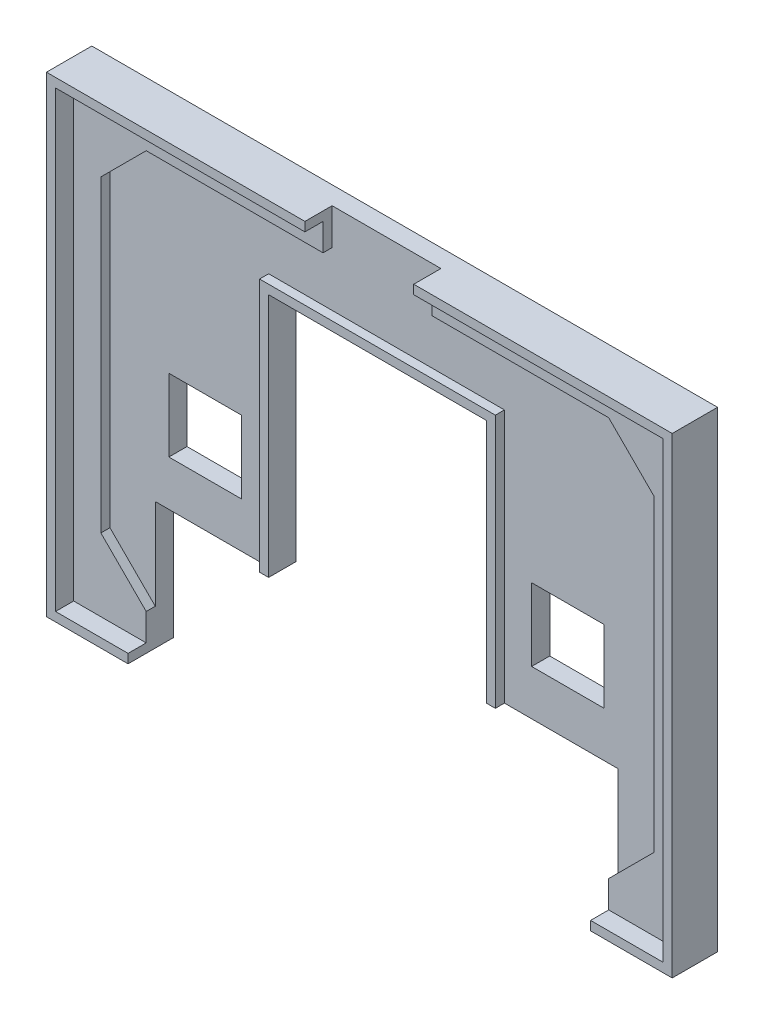
from build123d import *

# Parameters (mm, degrees)
SKICA1_W                    = 67
SKICA1_H                    = 50
P_IDAT_VYSUNUT_M1_DEPTH     = 3
ODEBRAT_VYSUNUT_M1_DEPTH    = 1
SKICA3_W                    = 8
SKICA3_H                    = 8
ODEBRAT_VYSUNUT_M2_DEPTH    = 4
VYSUNOUT_TENKOST_NN_1_DEPTH = 1
VYSUNOUT_TENKOST_NN_2_DEPTH = 5
SKICA6_W                    = 12
SKICA6_H                    = 4
ODEBRAT_VYSUNUT_M3_DEPTH    = 4
ODEBRAT_VYSUNUT_M4_DEPTH    = 1
P_IDAT_START                = -1
SKICA9_W                    = 2
SKICA9_H                    = 2
P_IDAT_VYSUNUT_M3_DEPTH     = 1
ODEBRAT_VYSUNUT_M5_DEPTH    = 1


with BuildPart() as part:
    # Skica1 → Přidat vysunutím1 (new body)
    with BuildSketch(Plane.XY):
        Rectangle(SKICA1_W, SKICA1_H)
    extrude(amount=P_IDAT_VYSUNUT_M1_DEPTH)

    # Skica2 → Odebrat vysunutím1 (cut)
    with BuildSketch(Plane.XY.offset(3)):
        Polygon((-25.5, -22), (-30.5, -17), (-30.5, 17), (-25.5, 22), (25.5, 22), (30.5, 17), (30.5, -17), (25.5, -22), align=None)
    extrude(amount=-ODEBRAT_VYSUNUT_M1_DEPTH, mode=Mode.SUBTRACT)

    # Skica3 → Odebrat vysunutím2 (cut, through all)
    with BuildSketch(Plane(origin=(0, 0, 0), x_dir=(-1, 0, 0), z_dir=(0, 0, -1))):
        with Locations((20, -3)):
            Rectangle(SKICA3_W, SKICA3_H)
        with Locations((-20, -3)):
            Rectangle(SKICA3_W, SKICA3_H)
        Polygon((25.5, -25), (-25.5, -25), (-25.5, -12), (-12, -12), (-12, 15), (12, 15), (12, -12), (25.5, -12), align=None)
    extrude(amount=-ODEBRAT_VYSUNUT_M2_DEPTH, mode=Mode.SUBTRACT)

    # Skica4 → Vysunout tenkostěnný1 (add)
    with BuildSketch(Plane.XY.offset(2)):
        Polygon((-12, -12), (-12, 15), (12, 15), (12, -12), (13, -12), (13, 16), (-13, 16), (-13, -12), align=None)
    extrude(amount=VYSUNOUT_TENKOST_NN_1_DEPTH)

    # Skica5 → Vysunout tenkostěnný2 (add)
    with BuildSketch(Plane(origin=(0, 0, 0), x_dir=(-1, 0, 0), z_dir=(0, 0, -1))):
        Polygon((-25.5, -25), (-33.5, -25), (-33.5, 25), (33.5, 25), (33.5, -25), (25.5, -25), (25.5, -26), (34.5, -26), (34.5, 26), (-34.5, 26), (-34.5, -26), (-25.5, -26), align=None)
    extrude(amount=-VYSUNOUT_TENKOST_NN_2_DEPTH)

    # Skica6 → Odebrat vysunutím3 (cut, through all)
    with BuildSketch(Plane.XY.offset(2)):
        with Locations((0, 24)):
            Rectangle(SKICA6_W, SKICA6_H)
    extrude(amount=ODEBRAT_VYSUNUT_M3_DEPTH, mode=Mode.SUBTRACT)

    # Skica8 → Odebrat vysunutím4 (cut)
    with BuildSketch(Plane(origin=(0, 0, 0), x_dir=(-1, 0, 0), z_dir=(0, 0, -1))):
        Polygon((-30.278743415, 21.328839402), (-28.10976975, 21.328839402), (-28.10976975, 20.22863537), (-27.009565718, 20.22863537), (-27.009565718, 17.996792903), (-19.371006289, 17.996792903), (-19.371006289, 20.22863537), (-18.302236657, 20.22863537), (-18.302236657, 21.328839402), (-15.944656586, 21.328839402), (-15.944656586, 20.22863537), (-14.844452554, 20.22863537), (-14.844452554, 16.833720068), (-15.944656586, 16.833720068), (-15.944656586, 15.702081634), (-14.844452554, 15.702081634), (-14.844452554, 8.943685432), (-15.944656586, 8.943685432), (-15.944656586, 7.969219003), (-17.123446622, 7.969219003), (-17.123446622, 6.806146168), (-18.302236657, 6.806146168), (-18.302236657, 5.737376536), (-28.10976975, 5.737376536), (-28.10976975, 6.806146168), (-29.194256583, 6.806146168), (-29.194256583, 7.969219003), (-30.278743415, 7.969219003), (-30.278743415, 8.943685432), (-31.473250651, 8.943685432), (-31.473250651, 15.702081634), (-30.278743415, 15.702081634), (-30.278743415, 16.833720068), (-31.473250651, 16.833720068), (-31.473250651, 20.22863537), (-30.278743415, 20.22863537), align=None)
        Polygon((15.944656586, 15.702081634), (14.844452554, 15.702081634), (14.844452554, 8.943685432), (15.944656586, 8.943685432), (15.944656586, 7.969219003), (17.123446622, 7.969219003), (17.123446622, 6.806146168), (18.302236657, 6.806146168), (18.302236657, 5.737376536), (28.10976975, 5.737376536), (28.10976975, 6.806146168), (29.194256583, 6.806146168), (29.194256583, 7.969219003), (30.278743415, 7.969219003), (30.278743415, 8.943685432), (31.473250651, 8.943685432), (31.473250651, 15.702081634), (30.278743415, 15.702081634), (30.278743415, 16.833720068), (31.473250651, 16.833720068), (31.473250651, 20.22863537), (30.278743415, 20.22863537), (30.278743415, 21.328839402), (28.10976975, 21.328839402), (28.10976975, 20.22863537), (27.009565718, 20.22863537), (27.009565718, 17.996792903), (19.371006289, 17.996792903), (19.371006289, 20.22863537), (18.302236657, 20.22863537), (18.302236657, 21.328839402), (15.944656586, 21.328839402), (15.944656586, 20.22863537), (14.844452554, 20.22863537), (14.844452554, 16.833720068), (15.944656586, 16.833720068), align=None)
    extrude(amount=-ODEBRAT_VYSUNUT_M4_DEPTH, mode=Mode.SUBTRACT)

    # Skica9 → Přidat vysunutím3 (add)
    with BuildSketch(Plane(origin=(0, 0, 0), x_dir=(-1, 0, 0), z_dir=(0, 0, -1)).offset(P_IDAT_START)):
        with Locations((-26.964723749, 13.702081634)):
            Rectangle(SKICA9_W, SKICA9_H)
        with Locations((-19.415848257, 13.702081634)):
            Rectangle(SKICA9_W, SKICA9_H)
        Polygon((-24.98757766, 11.151300523), (-21.392994346, 11.151300523), (-21.392994346, 10.145181963), (-22.505020123, 10.145181963), (-22.505020123, 7.391594326), (-23.875551884, 7.391594326), (-23.875551884, 10.145181963), (-24.98757766, 10.145181963), align=None)
        Polygon((23.875551884, 7.391594326), (23.875551884, 10.145181963), (24.98757766, 10.145181963), (24.98757766, 11.151300523), (21.392994346, 11.151300523), (21.392994346, 10.145181963), (22.505020123, 10.145181963), (22.505020123, 7.391594326), align=None)
        with Locations((26.964723749, 13.702081634)):
            Rectangle(SKICA9_W, SKICA9_H)
        with Locations((19.415848257, 13.702081634)):
            Rectangle(SKICA9_W, SKICA9_H)
    extrude(amount=P_IDAT_VYSUNUT_M3_DEPTH)

    # Skica10 → Odebrat vysunutím5 (cut)
    with BuildSketch(Plane(origin=(0, 0, 0), x_dir=(-1, 0, 0), z_dir=(0, 0, -1))):
        with BuildLine():
            add(Edge.make_bspline(
                [(-10.582727319, 23.39271335), (-10.573259952, 23.400958941), (-10.553513234, 23.418157318), (-10.516641334, 23.427777943), (-10.472569663, 23.433829236), (-10.414070793, 23.438016941), (-10.330986018, 23.442724777), (-10.223964999, 23.449578695), (-10.092857378, 23.453468821), (-9.939124435, 23.459812678), (-9.76295879, 23.459240195), (-9.60091977, 23.461172213), (-9.455401555, 23.460865676), (-9.329316952, 23.460941515), (-9.189176224, 23.460917745), (-9.035393723, 23.460925066), (-8.867969151, 23.460922838), (-8.686489205, 23.46092351), (-8.490953859, 23.46092331), (-8.285910453, 23.460923361), (-8.080867046, 23.460923375), (-7.885331702, 23.460923277), (-7.703438355, 23.460923615), (-7.535600414, 23.460922487), (-7.381817831, 23.460926165), (-7.242090762, 23.460914311), (-7.116418703, 23.460952369), (-6.970491828, 23.460797764), (-6.807601248, 23.461778934), (-6.630269575, 23.458316766), (-6.475221244, 23.456624325), (-6.342953863, 23.452420356), (-6.234185053, 23.449282415), (-6.149792181, 23.444690684), (-6.09056308, 23.438992897), (-6.045553055, 23.431725162), (-6.009349124, 23.417847346), (-5.988748093, 23.400689035), (-5.979172131, 23.39271335)],
                knots=[0, 0, 0, 0, 3.7205e-05, 7.7602e-05, 0.000111452, 0.000171187, 0.00025319, 0.000361263, 0.000492816, 0.000646679, 0.000822789, 0.001021222, 0.001132838, 0.001259337, 0.001399477, 0.00155326, 0.001720685, 0.001901751, 0.0020977, 0.002307291, 0.002516881, 0.00271283, 0.002893897, 0.003062561, 0.003216344, 0.003355244, 0.003481743, 0.003593359, 0.003793028, 0.003970392, 0.004125434, 0.004258186, 0.004367385, 0.004451864, 0.004511714, 0.004545769, 0.004588604, 0.00462581, 0.00462581, 0.00462581, 0.00462581], degree=3))
            add(Edge.make_bspline(
                [(-5.979172131, 23.39271335), (-5.975595674, 23.386625652), (-5.966557437, 23.371241138), (-5.959473114, 23.339178377), (-5.952184823, 23.296219466), (-5.945829545, 23.241131616), (-5.943273265, 23.174027485), (-5.938513791, 23.094711583), (-5.938439843, 23.00328864), (-5.937501833, 22.938390558), (-5.937005947, 22.904081684)],
                knots=[0, 0, 0, 0, 2.1083e-05, 5.328e-05, 9.732e-05, 0.000152239, 0.000219312, 0.000298771, 0.000390553, 0.000493495, 0.000493495, 0.000493495, 0.000493495], degree=3))
            add(Edge.make_bspline(
                [(-5.937005947, 22.904081684), (-5.937498171, 22.868945841), (-5.938418929, 22.803220469), (-5.938550318, 22.710560665), (-5.943228764, 22.630824276), (-5.945862692, 22.563319503), (-5.952056821, 22.508606524), (-5.959468044, 22.466509871), (-5.966460548, 22.435566981), (-5.975591842, 22.421116075), (-5.979172131, 22.415450018)],
                knots=[0, 0, 0, 0, 0.000105423, 0.000197205, 0.000277902, 0.000344975, 0.000399895, 0.000442712, 0.000473717, 0.000493714, 0.000493714, 0.000493714, 0.000493714], degree=3))
            add(Edge.make_bspline(
                [(-5.979172131, 22.415450018), (-5.985181646, 22.410911543), (-6.001219339, 22.39879964), (-6.038746794, 22.392332444), (-6.089952027, 22.382819011), (-6.158086712, 22.375983294), (-6.242444556, 22.371564699), (-6.343353068, 22.367853878), (-6.460350731, 22.365501922), (-6.543866559, 22.364913973), (-6.588101441, 22.364602561)],
                knots=[0, 0, 0, 0, 2.2358e-05, 5.9666e-05, 0.00011125, 0.000179864, 0.000264342, 0.000364866, 0.000482709, 0.000615415, 0.000615415, 0.000615415, 0.000615415], degree=3))
            Line((-6.588101441, 22.364602561), (-6.725761631, 22.364602561))
            Line((-6.725761631, 22.364602561), (-6.776609089, 22.364602561))
            add(Edge.make_bspline(
                [(-6.776609089, 22.364602561), (-6.827457447, 22.364730148), (-6.922955058, 22.364969767), (-7.056061174, 22.363421839), (-7.169343578, 22.362208661), (-7.262748381, 22.361137044), (-7.336470006, 22.359505541), (-7.390416472, 22.354737825), (-7.424836394, 22.353276806), (-7.440541053, 22.348590582), (-7.445067129, 22.347240014)],
                knots=[0, 0, 0, 0, 0.000152542, 0.000286488, 0.000399351, 0.000492373, 0.000566825, 0.000620283, 0.000655207, 0.000669347, 0.000669347, 0.000669347, 0.000669347], degree=3))
            add(Edge.make_bspline(
                [(-7.445067129, 22.347240014), (-7.446443223, 22.34354785), (-7.451312657, 22.330482789), (-7.45080193, 22.299913101), (-7.454580217, 22.251867572), (-7.456358246, 22.184744174), (-7.458934514, 22.09922383), (-7.461744528, 21.995452871), (-7.462015983, 21.873067024), (-7.465543068, 21.732536246), (-7.466040581, 21.57295141), (-7.467524661, 21.395194836), (-7.468569513, 21.198831445), (-7.47035845, 20.9842827), (-7.469336542, 20.751123526), (-7.471649177, 20.499371353), (-7.47091714, 20.229008862), (-7.471300579, 19.946248321), (-7.470570652, 19.663484176), (-7.472895172, 19.393129047), (-7.471835305, 19.140953792), (-7.473760116, 18.906976491), (-7.474370459, 18.690762596), (-7.477273524, 18.493167265), (-7.479606275, 18.31375231), (-7.482273132, 18.152531845), (-7.484154518, 18.00947546), (-7.488277966, 17.884639163), (-7.491823324, 17.778000793), (-7.495581711, 17.689463586), (-7.498790894, 17.619302805), (-7.503442189, 17.567128403), (-7.508472149, 17.534028387), (-7.512992075, 17.507615719), (-7.542865593, 17.496005673), (-7.584746004, 17.487996237), (-7.649726038, 17.479324916), (-7.73505743, 17.472146899), (-7.842755923, 17.467926736), (-7.971699373, 17.464149792), (-8.121788725, 17.461936316), (-8.285910465, 17.460384106), (-8.450032135, 17.461934632), (-8.600121663, 17.46415524), (-8.72865196, 17.467898568), (-8.835938054, 17.472157956), (-8.921249013, 17.479450796), (-8.986688197, 17.487887371), (-9.028955219, 17.496009703), (-9.058828853, 17.507615208), (-9.063348713, 17.534028637), (-9.068379112, 17.567128259), (-9.073027365, 17.619302928), (-9.076254144, 17.68946319), (-9.079918596, 17.778002776), (-9.083922979, 17.884619327), (-9.085884919, 18.009499327), (-9.088481744, 18.152527491), (-9.090919885, 18.313753674), (-9.093324287, 18.493166838), (-9.096205033, 18.690762726), (-9.096822195, 18.906976451), (-9.098744944, 19.140953804), (-9.097685693, 19.393129044), (-9.10001003, 19.663484177), (-9.099280157, 19.946248321), (-9.099663581, 20.229008862), (-9.098931547, 20.499371353), (-9.101244182, 20.751123526), (-9.100222274, 20.9842827), (-9.102011211, 21.198831445), (-9.103056062, 21.395194836), (-9.104540142, 21.57295141), (-9.105037655, 21.732536246), (-9.108564741, 21.873067024), (-9.108836196, 21.995452871), (-9.11164621, 22.09922383), (-9.114222478, 22.184744174), (-9.116000506, 22.251867572), (-9.119778794, 22.299913101), (-9.119268066, 22.330482789), (-9.124137501, 22.34354785), (-9.125513595, 22.347240014)],
                knots=[0, 0, 0, 0, 1.1765e-05, 4.1633e-05, 9.0064e-05, 0.000157079, 0.000242688, 0.000346893, 0.000468437, 0.000609839, 0.000768587, 0.000947178, 0.001143131, 0.001357686, 0.00159084, 0.0018426, 0.002112959, 0.002401922, 0.002690884, 0.002961247, 0.003213004, 0.003447401, 0.003663196, 0.003861641, 0.004040245, 0.004201487, 0.00434537, 0.004469444, 0.004576164, 0.004665535, 0.004735085, 0.004787408, 0.004821258, 0.004838127, 0.004862587, 0.004907113, 0.004970955, 0.00505685, 0.00516486, 0.005293893, 0.005443975, 0.005615125, 0.005786274, 0.005936357, 0.006065389, 0.00617216, 0.006258056, 0.006323127, 0.006367653, 0.006392113, 0.006408981, 0.006442832, 0.006495155, 0.006564705, 0.006654075, 0.006760796, 0.006884839, 0.007028721, 0.007189964, 0.007368568, 0.007567012, 0.007782807, 0.008017205, 0.008268962, 0.008539324, 0.008828287, 0.009117249, 0.009387609, 0.009639369, 0.009872523, 0.010087078, 0.010283031, 0.010461621, 0.010620369, 0.010761772, 0.010883316, 0.010987521, 0.011073129, 0.011140145, 0.011188576, 0.011218443, 0.011230209, 0.011230209, 0.011230209, 0.011230209], degree=3))
            add(Edge.make_bspline(
                [(-9.125513595, 22.347240014), (-9.130039554, 22.348589692), (-9.145349196, 22.353155152), (-9.17932304, 22.354863746), (-9.232463864, 22.359425371), (-9.305348987, 22.36116817), (-9.397517522, 22.362199864), (-9.509145125, 22.363419186), (-9.640597973, 22.36497404), (-9.734855409, 22.364732046), (-9.785290362, 22.364602561)],
                knots=[0, 0, 0, 0, 1.414e-05, 4.7831e-05, 0.000101289, 0.000174501, 0.000266283, 0.000377907, 0.000509372, 0.000660674, 0.000660674, 0.000660674, 0.000660674], degree=3))
            Line((-9.785290362, 22.364602561), (-9.844819093, 22.364602561))
            Line((-9.844819093, 22.364602561), (-9.982479283, 22.364602561))
            add(Edge.make_bspline(
                [(-9.982479283, 22.364602561), (-10.026714164, 22.364913973), (-10.110229993, 22.365501922), (-10.227227656, 22.367853878), (-10.328136168, 22.371564699), (-10.412494011, 22.375983294), (-10.480628696, 22.382819011), (-10.53183393, 22.392332444), (-10.569361385, 22.39879964), (-10.585399078, 22.410911543), (-10.591408593, 22.415450018)],
                knots=[0, 0, 0, 0, 0.000132705, 0.000250549, 0.000351072, 0.00043555, 0.000504165, 0.000555748, 0.000593057, 0.000615415, 0.000615415, 0.000615415, 0.000615415], degree=3))
            add(Edge.make_bspline(
                [(-10.591408593, 22.415450018), (-10.594991362, 22.421115837), (-10.604128978, 22.435566133), (-10.611044111, 22.46651647), (-10.618923035, 22.508526159), (-10.622551067, 22.56347001), (-10.628118131, 22.630740204), (-10.631777347, 22.710579576), (-10.632240019, 22.803214624), (-10.633109803, 22.868943804), (-10.633574777, 22.904081684)],
                knots=[0, 0, 0, 0, 1.9997e-05, 5.1002e-05, 9.382e-05, 0.000148613, 0.000215766, 0.000296464, 0.000388245, 0.000493668, 0.000493668, 0.000493668, 0.000493668], degree=3))
            add(Edge.make_bspline(
                [(-10.633574777, 22.904081684), (-10.633270278, 22.937981604), (-10.63269833, 23.001656574), (-10.630256496, 23.091792905), (-10.626563571, 23.170357252), (-10.622295525, 23.237452327), (-10.614860166, 23.292569211), (-10.606102988, 23.335892685), (-10.597893992, 23.369514896), (-10.587215505, 23.385848367), (-10.582727319, 23.39271335)],
                knots=[0, 0, 0, 0, 0.000101702, 0.00019103, 0.000270489, 0.000337642, 0.000392715, 0.000436981, 0.000470718, 0.000495178, 0.000495178, 0.000495178, 0.000495178], degree=3))
        make_face()
        with BuildLine():
            add(Edge.make_bspline(
                [(-5.070118803, 22.980972962), (-5.069456256, 23.01074326), (-5.068213546, 23.066582032), (-5.064023992, 23.145098878), (-5.060725313, 23.213353525), (-5.056166889, 23.271333482), (-5.049542007, 23.318763899), (-5.044135986, 23.355917804), (-5.037147161, 23.382627258), (-5.024600594, 23.409144268), (-4.982249469, 23.426128617), (-4.914640972, 23.439134747), (-4.812092949, 23.447545477), (-4.7187853, 23.451470868), (-4.641015263, 23.453563068), (-4.586458749, 23.455195041), (-4.521123796, 23.454287467), (-4.445069697, 23.456135745), (-4.357846656, 23.457640703), (-4.2594478, 23.456667354), (-4.149909746, 23.459080828), (-4.030014732, 23.457870858), (-3.898978274, 23.460214832), (-3.75717915, 23.459618161), (-3.604220896, 23.459314749), (-3.440523151, 23.461399874), (-3.265653622, 23.460783033), (-3.079627018, 23.460964633), (-2.882851296, 23.460910626), (-2.678634719, 23.460929877), (-2.474831536, 23.460910695), (-2.278055818, 23.460963914), (-2.092442594, 23.460784473), (-1.91715972, 23.461396343), (-1.753048505, 23.459318117), (-1.599676901, 23.459617157), (-1.457877769, 23.46021505), (-1.326841313, 23.457870865), (-1.206946295, 23.459080632), (-1.097821595, 23.45667713), (-0.999422853, 23.457628979), (-0.912199881, 23.456149241), (-0.835731267, 23.454287482), (-0.770400257, 23.455192768), (-0.71583251, 23.453569839), (-0.638115826, 23.45143382), (-0.543818949, 23.447967487), (-0.442624567, 23.438044247), (-0.370890736, 23.428468569), (-0.340204568, 23.408681742), (-0.328903425, 23.401394624)],
                knots=[0, 0, 0, 0, 8.9328e-05, 0.000167548, 0.000235859, 0.000294358, 0.000341891, 0.00037961, 0.000406696, 0.000425007, 0.000465002, 0.000533605, 0.000635783, 0.000771105, 0.000814529, 0.000869111, 0.000934841, 0.001010502, 0.001097324, 0.001196538, 0.001305681, 0.001425979, 0.001556204, 0.001698825, 0.001851367, 0.002015076, 0.002189941, 0.002375969, 0.002573158, 0.002780268, 0.002988619, 0.003184567, 0.003370595, 0.00354546, 0.003710409, 0.003862951, 0.004005572, 0.004135797, 0.004256095, 0.004365238, 0.004463212, 0.004551274, 0.004626935, 0.004692665, 0.004747247, 0.004790671, 0.004925993, 0.005029405, 0.005098009, 0.005138003, 0.005138003, 0.005138003, 0.005138003], degree=3))
            add(Edge.make_bspline(
                [(-0.328903425, 23.401394624), (-0.324402309, 23.394110947), (-0.313535652, 23.376526596), (-0.305808855, 23.341186566), (-0.296607033, 23.295897228), (-0.289546462, 23.239490044), (-0.285014324, 23.17160436), (-0.281364568, 23.092618203), (-0.278946741, 23.002070066), (-0.278364139, 22.937981696), (-0.278055967, 22.904081684)],
                knots=[0, 0, 0, 0, 2.5537e-05, 6.1652e-05, 0.000107134, 0.000164666, 0.000231819, 0.000311278, 0.000401845, 0.000503548, 0.000503548, 0.000503548, 0.000503548], degree=3))
            add(Edge.make_bspline(
                [(-0.278055967, 22.904081684), (-0.278548192, 22.868945841), (-0.27946895, 22.803220469), (-0.279600339, 22.710560665), (-0.284278784, 22.630824276), (-0.286912713, 22.563319503), (-0.293106842, 22.508606524), (-0.300518065, 22.466509871), (-0.307510569, 22.435566981), (-0.316641862, 22.421116075), (-0.320222152, 22.415450018)],
                knots=[0, 0, 0, 0, 0.000105423, 0.000197205, 0.000277902, 0.000344975, 0.000399895, 0.000442712, 0.000473717, 0.000493714, 0.000493714, 0.000493714, 0.000493714], degree=3))
            add(Edge.make_bspline(
                [(-0.320222152, 22.415450018), (-0.324293609, 22.413223039), (-0.335872461, 22.406889711), (-0.361023883, 22.402182198), (-0.397401954, 22.397390889), (-0.445452785, 22.392633201), (-0.505384399, 22.387757113), (-0.577293602, 22.38251114), (-0.661269916, 22.37939722), (-0.757168554, 22.375474998), (-0.8650714, 22.371932066), (-0.984937012, 22.367827059), (-1.116833328, 22.365851501), (-1.260277442, 22.363218336), (-1.41571577, 22.36087539), (-1.583131605, 22.357976683), (-1.762554591, 22.357227217), (-1.886158849, 22.356365246), (-1.94982116, 22.355921287)],
                knots=[0, 0, 0, 0, 1.3866e-05, 3.9433e-05, 7.5738e-05, 0.000124359, 0.000184094, 0.000256196, 0.00034061, 0.000436177, 0.000544137, 0.000664492, 0.000795974, 0.000939857, 0.001094899, 0.001262342, 0.001442173, 0.001633165, 0.001633165, 0.001633165, 0.001633165], degree=3))
            Line((-1.94982116, 22.355921287), (-3.534773619, 22.347240014))
            Line((-3.534773619, 22.347240014), (-3.534773619, 21.026446298))
            Line((-3.534773619, 21.026446298), (-2.274748816, 21.017765025))
            add(Edge.make_bspline(
                [(-2.274748816, 21.017765025), (-2.17760358, 21.016989399), (-1.995295298, 21.015533815), (-1.740583296, 21.01274529), (-1.522828299, 21.005431457), (-1.342314082, 21.00090411), (-1.199735882, 20.991275975), (-1.092693487, 20.984271734), (-1.025325384, 20.974084748), (-0.981605538, 20.963591655), (-0.966262627, 20.936654136), (-0.957654989, 20.904505415), (-0.947471131, 20.860647816), (-0.940592509, 20.804210424), (-0.936123338, 20.735879251), (-0.932409137, 20.655249818), (-0.93016354, 20.562217739), (-0.9286146, 20.460923573), (-0.930160778, 20.359628149), (-0.932418169, 20.266599264), (-0.936096179, 20.185960386), (-0.940671009, 20.117656715), (-0.947205665, 20.061543156), (-0.958111643, 20.017888862), (-0.965987535, 19.985521225), (-0.981632328, 19.958288618), (-1.025213648, 19.947546466), (-1.092941242, 19.939900084), (-1.199545408, 19.929201565), (-1.342445023, 19.923597073), (-1.522742542, 19.915054484), (-1.740638057, 19.911574309), (-1.995270205, 19.905544869), (-2.177597298, 19.904590312), (-2.274748816, 19.904081684)],
                knots=[0, 0, 0, 0, 0.000291453, 0.000546958, 0.000764078, 0.000945251, 0.001088136, 0.001193908, 0.00126425, 0.001297642, 0.00132, 0.001352553, 0.001398289, 0.001454591, 0.001522981, 0.001603679, 0.001696726, 0.001802148, 0.001907571, 0.002000618, 0.002081316, 0.002149706, 0.002206008, 0.002250534, 0.00228427, 0.002306628, 0.002340021, 0.002410176, 0.002516057, 0.002658872, 0.002840092, 0.00305718, 0.003312706, 0.003604159, 0.003604159, 0.003604159, 0.003604159], degree=3))
            Line((-2.274748816, 19.904081684), (-3.534773619, 19.895400411))
            Line((-3.534773619, 19.895400411), (-3.534773619, 18.575846877))
            Line((-3.534773619, 18.575846877), (-1.94982116, 18.567165603))
            add(Edge.make_bspline(
                [(-1.94982116, 18.567165603), (-1.886158849, 18.566721645), (-1.762554591, 18.565859674), (-1.583131606, 18.565110206), (-1.415715769, 18.562211509), (-1.260277446, 18.559868527), (-1.116833314, 18.55723548), (-0.984937058, 18.555259538), (-0.865071252, 18.551155778), (-0.757169021, 18.547608882), (-0.661268463, 18.543699036), (-0.577298055, 18.540547047), (-0.505371395, 18.535413587), (-0.445489294, 18.530218398), (-0.397241047, 18.526319724), (-0.361132856, 18.519379496), (-0.33586775, 18.514987506), (-0.324292383, 18.508631607), (-0.320222152, 18.506396691)],
                knots=[0, 0, 0, 0, 0.000190992, 0.000370823, 0.000538266, 0.000693308, 0.000837191, 0.000968673, 0.001089029, 0.001196988, 0.001292555, 0.001376969, 0.001449071, 0.001508806, 0.001557427, 0.001593923, 0.00161949, 0.001633355, 0.001633355, 0.001633355, 0.001633355], degree=3))
            add(Edge.make_bspline(
                [(-0.320222152, 18.506396691), (-0.316654969, 18.500727541), (-0.307769122, 18.486605699), (-0.300246605, 18.456247843), (-0.293191254, 18.414456336), (-0.286818977, 18.359366177), (-0.284377941, 18.291841621), (-0.279531238, 18.211703253), (-0.279495527, 18.119038534), (-0.278555403, 18.05290052), (-0.278055967, 18.017765025)],
                knots=[0, 0, 0, 0, 1.9997e-05, 4.9813e-05, 9.2631e-05, 0.00014755, 0.000215862, 0.00029532, 0.000388342, 0.000493765, 0.000493765, 0.000493765, 0.000493765], degree=3))
            add(Edge.make_bspline(
                [(-0.278055967, 18.017765025), (-0.278361946, 17.983865341), (-0.278936672, 17.920190813), (-0.28136027, 17.830051577), (-0.285130029, 17.751084533), (-0.289288455, 17.683142364), (-0.296997517, 17.626449278), (-0.305305497, 17.581336275), (-0.314116251, 17.545994562), (-0.324438097, 17.528165225), (-0.328903425, 17.520452085)],
                knots=[0, 0, 0, 0, 0.000101702, 0.00019103, 0.000270489, 0.000338879, 0.000395181, 0.000441882, 0.000476806, 0.000503433, 0.000503433, 0.000503433, 0.000503433], degree=3))
            add(Edge.make_bspline(
                [(-0.328903425, 17.520452085), (-0.340244342, 17.513647835), (-0.371335085, 17.49499421), (-0.44257205, 17.485102432), (-0.543763572, 17.473324057), (-0.638116935, 17.470459853), (-0.715832307, 17.468268253), (-0.77040033, 17.466657029), (-0.835731242, 17.467558191), (-0.912199889, 17.465697815), (-0.99942285, 17.464217619), (-1.097821596, 17.465169614), (-1.206946295, 17.462766066), (-1.326841313, 17.463975848), (-1.457877768, 17.461631657), (-1.599676901, 17.462229552), (-1.753048505, 17.462528592), (-1.91715972, 17.460450366), (-2.092442594, 17.461062236), (-2.278055818, 17.460882795), (-2.474831536, 17.460936013), (-2.678634719, 17.460916832), (-2.882851296, 17.460936083), (-3.079627018, 17.460882076), (-3.265653622, 17.461063676), (-3.440523151, 17.460446835), (-3.604220896, 17.46253196), (-3.75717915, 17.462228548), (-3.898978274, 17.461631876), (-4.030014732, 17.463975854), (-4.149909746, 17.462765871), (-4.259447801, 17.465179388), (-4.357846654, 17.464205902), (-4.445069704, 17.465711283), (-4.521123775, 17.467558272), (-4.58645881, 17.466654557), (-4.641015093, 17.468275581), (-4.718786228, 17.470419773), (-4.812124471, 17.473784716), (-4.914751916, 17.483910692), (-4.981697234, 17.497533927), (-5.024779814, 17.512739635), (-5.037121706, 17.539261229), (-5.044147257, 17.565910384), (-5.049537699, 17.603090026), (-5.056168031, 17.650510585), (-5.06072712, 17.708494046), (-5.064013135, 17.776747759), (-5.068263995, 17.85526373), (-5.069679968, 17.929297828), (-5.071850858, 17.999565328), (-5.070921063, 18.067379535), (-5.072803029, 18.148808224), (-5.074260633, 18.244299913), (-5.07334113, 18.353445595), (-5.075612765, 18.476627497), (-5.075002855, 18.613466241), (-5.074730643, 18.764357325), (-5.076775885, 18.928468662), (-5.076274998, 19.106644963), (-5.075943815, 19.298461873), (-5.078037302, 19.504327047), (-5.077419676, 19.723842335), (-5.077601285, 19.957409383), (-5.077547107, 20.20461913), (-5.077566445, 20.460923354), (-5.077547107, 20.717227579), (-5.077601285, 20.964437326), (-5.077419676, 21.198004374), (-5.078037302, 21.417519662), (-5.075943815, 21.623384835), (-5.076274999, 21.815201746), (-5.076775882, 21.993378047), (-5.074730654, 22.157489385), (-5.075002821, 22.308380467), (-5.075612877, 22.445219214), (-5.073340775, 22.568401107), (-5.074261738, 22.677546818), (-5.072799672, 22.773038416), (-5.07093086, 22.854467375), (-5.071823724, 22.922280823), (-5.07064714, 22.96278488), (-5.070118803, 22.980972962)],
                knots=[0, 0, 0, 0, 3.9394e-05, 0.000107998, 0.000211536, 0.000346858, 0.000390282, 0.000444864, 0.000510594, 0.000586255, 0.000674317, 0.000772291, 0.000881434, 0.001001732, 0.001131957, 0.001274578, 0.00142712, 0.001592069, 0.001766935, 0.001952962, 0.002148911, 0.002357261, 0.002564372, 0.00276156, 0.002947588, 0.003122453, 0.003286162, 0.003438704, 0.003581325, 0.00371155, 0.003831848, 0.003940991, 0.004040206, 0.004127027, 0.004202689, 0.004268418, 0.004323, 0.004366424, 0.004501746, 0.004604052, 0.004672655, 0.004712049, 0.004730361, 0.004757447, 0.004795165, 0.004842698, 0.004901198, 0.004969509, 0.005047729, 0.005137056, 0.005191639, 0.005258608, 0.00534047, 0.005435972, 0.005545108, 0.005667892, 0.005805552, 0.005955614, 0.006120563, 0.006297909, 0.006490137, 0.006696011, 0.006915524, 0.007148678, 0.007396714, 0.007657152, 0.00791759, 0.008165627, 0.008398781, 0.008618293, 0.008824167, 0.009016395, 0.009193741, 0.00935869, 0.009508752, 0.009646412, 0.009769197, 0.009878333, 0.009973835, 0.010055696, 0.010122666, 0.010177248, 0.010177248, 0.010177248, 0.010177248], degree=3))
        make_face()
        with BuildLine():
            add(Edge.make_bspline(
                [(0.56526772, 22.980972962), (0.565930255, 23.010743292), (0.567172942, 23.066582123), (0.571362647, 23.14509858), (0.574660858, 23.213354431), (0.579220659, 23.271330847), (0.585841726, 23.318771074), (0.591257696, 23.355899395), (0.598223214, 23.382668784), (0.610373564, 23.408012901), (0.647787777, 23.426592541), (0.708233692, 23.438420167), (0.797054206, 23.447863303), (0.893028059, 23.452044285), (1.000556401, 23.455428338), (1.122109457, 23.455919568), (1.280851252, 23.457403043), (1.476800966, 23.458536321), (1.710368616, 23.459717966), (1.98114026, 23.461314397), (2.2895342, 23.460805545), (2.507392653, 23.460882574), (2.622729481, 23.460923354)],
                knots=[0, 0, 0, 0, 8.9328e-05, 0.000167548, 0.000235859, 0.000294358, 0.000341891, 0.00037961, 0.000406696, 0.000425007, 0.000461818, 0.000524382, 0.00061176, 0.000728502, 0.000812871, 0.000934415, 0.001093163, 0.001289116, 0.001522273, 0.001793876, 0.002101441, 0.002447452, 0.002447452, 0.002447452, 0.002447452], degree=3))
            add(Edge.make_bspline(
                [(2.622729481, 23.460923354), (2.702101732, 23.461104584), (2.855886615, 23.461455718), (3.079112256, 23.459002719), (3.287478868, 23.460691903), (3.480512927, 23.456633519), (3.658704688, 23.456500986), (3.821987382, 23.453537401), (3.970805846, 23.451017866), (4.104772654, 23.449098877), (4.223803527, 23.444840814), (4.328032882, 23.441790085), (4.417286805, 23.436471592), (4.491750565, 23.431772366), (4.551204158, 23.426702199), (4.596222956, 23.422545356), (4.625876699, 23.416791792), (4.648387436, 23.409517153), (4.661074554, 23.389130107), (4.672998444, 23.362147187), (4.684058185, 23.325824474), (4.692602931, 23.280167513), (4.697938869, 23.224940523), (4.703335619, 23.160480687), (4.705229448, 23.086809743), (4.705886012, 23.034713009), (4.706235062, 23.007016782)],
                knots=[0, 0, 0, 0, 0.000238115, 0.000461351, 0.000669702, 0.000863186, 0.001040536, 0.001204259, 0.001353102, 0.001487064, 0.00160618, 0.001710421, 0.001799852, 0.001874428, 0.001934163, 0.001979085, 0.002009488, 0.002025611, 0.002047691, 0.002077662, 0.002115319, 0.002160802, 0.002216953, 0.002281633, 0.002354846, 0.002437948, 0.002437948, 0.002437948, 0.002437948], degree=3))
            Line((4.706235062, 23.007016782), (4.706235062, 22.647364032))
            Line((4.706235062, 22.647364032), (4.98031526, 22.647364032))
            add(Edge.make_bspline(
                [(4.98031526, 22.647364032), (5.020555418, 22.647215738), (5.092637249, 22.6469501), (5.18678328, 22.632605132), (5.260004576, 22.61590391), (5.292560761, 22.589293521), (5.306483098, 22.577913846)],
                knots=[0, 0, 0, 0, 0.000120355, 0.000215591, 0.000286985, 0.000340327, 0.000340327, 0.000340327, 0.000340327], degree=3))
            add(Edge.make_bspline(
                [(5.306483098, 22.577913846), (5.311895737, 22.566068407), (5.32644067, 22.534237142), (5.335442598, 22.468111707), (5.343955917, 22.374778195), (5.348492587, 22.273263603), (5.351813506, 22.160826452), (5.352338886, 22.033882163), (5.353804549, 21.868119686), (5.35494415, 21.663486144), (5.356123712, 21.419997945), (5.357723281, 21.137650921), (5.357212745, 20.816441942), (5.357289835, 20.589488801), (5.357330556, 20.469604628)],
                knots=[0, 0, 0, 0, 3.8923e-05, 0.000104594, 0.000198012, 0.000320946, 0.000409034, 0.000535539, 0.000701728, 0.000906361, 0.00114944, 0.001432205, 0.001753412, 0.002113064, 0.002113064, 0.002113064, 0.002113064], degree=3))
            add(Edge.make_bspline(
                [(5.357330556, 20.469604628), (5.357497089, 20.386925383), (5.357820166, 20.226526548), (5.35555655, 19.993377398), (5.35660015, 19.775513205), (5.354702588, 19.573367393), (5.354004704, 19.386917881), (5.351370599, 19.215776401), (5.348111565, 19.05994548), (5.348500101, 18.919339828), (5.343234629, 18.794140091), (5.34189461, 18.684125396), (5.337775824, 18.589469624), (5.334002184, 18.510533331), (5.331047298, 18.44673432), (5.325696187, 18.398884165), (5.321958689, 18.365851736), (5.316949205, 18.349690841), (5.315164372, 18.343932863)],
                knots=[0, 0, 0, 0, 0.000248036, 0.000481194, 0.000699466, 0.000901619, 0.001087651, 0.001258814, 0.001415096, 0.001555242, 0.001680556, 0.00179096, 0.001885287, 0.001964746, 0.002028105, 0.002076726, 0.00210935, 0.002127407, 0.002127407, 0.002127407, 0.002127407], degree=3))
            add(Edge.make_bspline(
                [(5.315164372, 18.343932863), (5.306155772, 18.328930534), (5.288970639, 18.300311544), (5.246414864, 18.281807726), (5.20199084, 18.278690407), (5.148539445, 18.278571952), (5.075432148, 18.274665264), (5.02000907, 18.275343401), (4.988996534, 18.275722858)],
                knots=[0, 0, 0, 0, 5.1344e-05, 9.7946e-05, 0.000131637, 0.000184979, 0.000258192, 0.000351206, 0.000351206, 0.000351206, 0.000351206], degree=3))
            Line((4.988996534, 18.275722858), (4.706235062, 18.275722858))
            Line((4.706235062, 18.275722858), (4.706235062, 17.923511201))
            add(Edge.make_bspline(
                [(4.706235062, 17.923511201), (4.705760813, 17.895815817), (4.704868929, 17.843731174), (4.704520965, 17.770088094), (4.700462512, 17.705582891), (4.695765672, 17.650157575), (4.689955282, 17.604084924), (4.682337811, 17.567746275), (4.675050223, 17.539913958), (4.666389973, 17.526123154), (4.662828696, 17.520452085)],
                knots=[0, 0, 0, 0, 8.3101e-05, 0.000156283, 0.000220879, 0.000276908, 0.000323211, 0.000359938, 0.00038857, 0.000408568, 0.000408568, 0.000408568, 0.000408568], degree=3))
            add(Edge.make_bspline(
                [(4.662828696, 17.520452085), (4.655465103, 17.512643359), (4.638418369, 17.494566139), (4.602000269, 17.486505319), (4.558789083, 17.482644311), (4.50373318, 17.477065319), (4.427594444, 17.474691047), (4.331340249, 17.468685083), (4.214313339, 17.465459954), (4.07746369, 17.463461089), (3.920386208, 17.460085575), (3.776097681, 17.461047019), (3.647533334, 17.46089574), (3.537570257, 17.460931997), (3.41603252, 17.460920666), (3.282919636, 17.460924164), (3.138231757, 17.46092311), (2.98238223, 17.460923427), (2.814957675, 17.460923334), (2.699620759, 17.460923348), (2.640092028, 17.460923354)],
                knots=[0, 0, 0, 0, 3.1619e-05, 7.3197e-05, 0.000106888, 0.000162916, 0.000238659, 0.00033552, 0.000452157, 0.000589839, 0.000746122, 0.000923468, 0.001022682, 0.001131818, 0.001253356, 0.001387296, 0.001531157, 0.00168742, 0.001854844, 0.00203343, 0.00203343, 0.00203343, 0.00203343], degree=3))
            add(Edge.make_bspline(
                [(2.640092028, 17.460923354), (2.524341809, 17.460964175), (2.30524318, 17.461041442), (1.995195626, 17.460529884), (1.722357159, 17.462134159), (1.487135539, 17.463307368), (1.289533279, 17.464442835), (1.129548586, 17.465934424), (1.006762347, 17.466403839), (0.897975575, 17.469856139), (0.800384154, 17.473702936), (0.71005667, 17.484263965), (0.649506888, 17.497509589), (0.610309423, 17.513494192), (0.598259531, 17.539239115), (0.59124161, 17.565920188), (0.585847911, 17.603086205), (0.579218828, 17.650511989), (0.574659288, 17.708493564), (0.571373426, 17.776747918), (0.567122516, 17.855263677), (0.565706558, 17.929297837), (0.563535665, 17.999565325), (0.564465461, 18.067379536), (0.562583494, 18.148808224), (0.561125891, 18.244299913), (0.562045394, 18.353445595), (0.559773759, 18.476627497), (0.560383668, 18.613466241), (0.56065588, 18.764357325), (0.558610638, 18.928468662), (0.559111525, 19.106644963), (0.559442708, 19.298461873), (0.557349222, 19.504327047), (0.557966847, 19.723842335), (0.557785239, 19.957409383), (0.557839416, 20.20461913), (0.557820079, 20.460923354), (0.557839416, 20.717227579), (0.557785239, 20.964437326), (0.557966847, 21.198004374), (0.557349221, 21.417519662), (0.559442709, 21.623384835), (0.559111524, 21.815201746), (0.558610642, 21.993378047), (0.560655869, 22.157489385), (0.560383703, 22.308380467), (0.559773646, 22.445219214), (0.562045749, 22.568401107), (0.561124785, 22.677546818), (0.562586851, 22.773038416), (0.564455664, 22.854467375), (0.563562799, 22.922280823), (0.564739383, 22.96278488), (0.56526772, 22.980972962)],
                knots=[0, 0, 0, 0, 0.000347251, 0.000657296, 0.000930139, 0.001165777, 0.00136297, 0.001522958, 0.001645742, 0.001731351, 0.001849331, 0.001939319, 0.002001884, 0.00203911, 0.002057421, 0.002084507, 0.002122226, 0.002169759, 0.002228258, 0.00229657, 0.00237479, 0.002464117, 0.002518699, 0.002585669, 0.00266753, 0.002763032, 0.002872168, 0.002994953, 0.003132613, 0.003282675, 0.003447624, 0.00362497, 0.003817198, 0.004023072, 0.004242584, 0.004475738, 0.004723775, 0.004984213, 0.005244651, 0.005492687, 0.005725842, 0.005945354, 0.006151228, 0.006343456, 0.006520802, 0.006685751, 0.006835813, 0.006973473, 0.007096257, 0.007205393, 0.007300895, 0.007382757, 0.007449727, 0.007504309, 0.007504309, 0.007504309, 0.007504309], degree=3))
        make_face()
        with BuildLine():
            add(Edge.make_bspline(
                [(3.814544281, 18.575846877), (3.814544281, 18.580807604), (3.814544281, 18.600650514), (3.814544281, 18.644883669), (3.814544281, 18.718467794), (3.814544281, 18.821402891), (3.814544281, 18.954102354), (3.814544281, 19.116152788), (3.814544281, 19.307554194), (3.814544281, 19.528306571), (3.814544281, 19.778823313), (3.814544281, 20.058691027), (3.814544281, 20.368323106), (3.814544281, 20.707306157), (3.814544281, 21.07564018), (3.814544281, 21.473325173), (3.814544281, 21.900361139), (3.814544281, 22.195111035), (3.814544281, 22.347240014)],
                knots=[0, 0, 0, 0, 1.4882e-05, 5.9529e-05, 0.000132699, 0.000235635, 0.000368334, 0.000530798, 0.000721786, 0.000942538, 0.001193055, 0.001473336, 0.001782141, 0.002121951, 0.002490285, 0.002887143, 0.003315006, 0.003771393, 0.003771393, 0.003771393, 0.003771393], degree=3))
            Line((3.814544281, 22.347240014), (2.966259866, 22.355921287))
            add(Edge.make_bspline(
                [(2.966259866, 22.355921287), (2.964192896, 22.355921287), (2.95633841, 22.355921287), (2.93856247, 22.355921287), (2.909211498, 22.355921287), (2.867872102, 22.355921287), (2.814957675, 22.355921287), (2.750054822, 22.355921287), (2.673576939, 22.355921287), (2.618595541, 22.355921287), (2.58924457, 22.355921287)],
                knots=[0, 0, 0, 0, 6.201e-06, 2.3563e-05, 5.3328e-05, 9.4254e-05, 0.000147582, 0.000212071, 0.000288962, 0.000377015, 0.000377015, 0.000377015, 0.000377015], degree=3))
            add(Edge.make_bspline(
                [(2.58924457, 22.355921287), (2.551620444, 22.356198576), (2.48132315, 22.356716665), (2.383389262, 22.353390134), (2.300200266, 22.351598389), (2.232116692, 22.347738628), (2.177855474, 22.343753241), (2.13990124, 22.336432211), (2.112670297, 22.333559446), (2.10374614, 22.324408911), (2.100612904, 22.321196194)],
                knots=[0, 0, 0, 0, 0.000112857, 0.000210862, 0.000293992, 0.000362303, 0.000415861, 0.000456028, 0.000480394, 0.000493577, 0.000493577, 0.000493577, 0.000493577], degree=3))
            add(Edge.make_bspline(
                [(2.100612904, 22.321196194), (2.100612904, 22.317062255), (2.100612904, 22.300113102), (2.100612904, 22.28316395), (2.100612904, 22.270348737)],
                knots=[0, 0, 0, 0, 1.2402e-05, 5.0847e-05, 5.0847e-05, 5.0847e-05, 5.0847e-05], degree=3))
            add(Edge.make_bspline(
                [(2.100612904, 22.270348737), (2.100604483, 22.249678971), (2.100585116, 22.202138511), (2.100775899, 22.12276571), (2.099832304, 22.027240584), (2.094918252, 21.916514893), (2.092941455, 21.788338167), (2.091621163, 21.644060089), (2.092013773, 21.487793573), (2.091959222, 21.380724795), (2.091931631, 21.326570316)],
                knots=[0, 0, 0, 0, 6.2009e-05, 0.000142621, 0.000238123, 0.000348562, 0.000475085, 0.000622672, 0.000781415, 0.000943879, 0.000943879, 0.000943879, 0.000943879], degree=3))
            add(Edge.make_bspline(
                [(2.091931631, 21.326570316), (2.091855814, 21.301766184), (2.091681426, 21.244714031), (2.093418704, 21.148399734), (2.094570035, 21.030582208), (2.095208816, 20.897869453), (2.098505472, 20.762297931), (2.099066944, 20.636612864), (2.100918007, 20.526657248), (2.100709518, 20.458856988), (2.100612904, 20.427438443)],
                knots=[0, 0, 0, 0, 7.4411e-05, 0.000171153, 0.000288977, 0.000427883, 0.000569285, 0.00069579, 0.000804933, 0.000899187, 0.000899187, 0.000899187, 0.000899187], degree=3))
            Line((2.100612904, 20.427438443), (2.100612904, 18.575846877))
            Line((2.100612904, 18.575846877), (3.814544281, 18.575846877))
        make_face(mode=Mode.SUBTRACT)
        with BuildLine():
            add(Edge.make_bspline(
                [(6.24406061, 23.39271335), (6.251187581, 23.399745372), (6.266916947, 23.415265184), (6.30105195, 23.431082827), (6.344581496, 23.440596505), (6.388059342, 23.44881359), (6.432979536, 23.451211908), (6.480087968, 23.453828533), (6.539632693, 23.45612648), (6.611132185, 23.458850034), (6.695070504, 23.460040967), (6.790985246, 23.459203992), (6.899284949, 23.461432987), (6.975353594, 23.461099274), (7.015453747, 23.460923354)],
                knots=[0, 0, 0, 0, 2.9868e-05, 6.5918e-05, 0.000110737, 0.000163543, 0.000198356, 0.000245549, 0.000305129, 0.000377102, 0.000460204, 0.000556938, 0.000664841, 0.000785138, 0.000785138, 0.000785138, 0.000785138], degree=3))
            add(Edge.make_bspline(
                [(7.015453747, 23.460923354), (7.072500889, 23.460427581), (7.17956802, 23.459497103), (7.329662108, 23.459413082), (7.458627708, 23.454706191), (7.566136729, 23.452032964), (7.651954707, 23.446273806), (7.715685176, 23.438090963), (7.759852496, 23.432858889), (7.77992481, 23.422373223), (7.786846885, 23.41875717)],
                knots=[0, 0, 0, 0, 0.00017115, 0.000321217, 0.000450249, 0.000558209, 0.000644006, 0.000707692, 0.000751958, 0.000775259, 0.000775259, 0.000775259, 0.000775259], degree=3))
            add(Edge.make_bspline(
                [(7.786846885, 23.41875717), (7.791345838, 23.411045773), (7.803823728, 23.389658139), (7.811662259, 23.341925166), (7.822310412, 23.274492022), (7.82813198, 23.183919716), (7.83654655, 23.072465328), (7.840150092, 22.93838087), (7.846131358, 22.783003516), (7.847100631, 22.671762994), (7.847615798, 22.612638939)],
                knots=[0, 0, 0, 0, 2.6628e-05, 7.3853e-05, 0.00014278, 0.000232383, 0.000345485, 0.000478277, 0.000634618, 0.000811982, 0.000811982, 0.000811982, 0.000811982], degree=3))
            add(Edge.make_bspline(
                [(7.847615798, 22.612638939), (7.84764298, 22.572539895), (7.847697345, 22.492341806), (7.847299409, 22.374933135), (7.848651354, 22.264966034), (7.850600696, 22.166546451), (7.855579657, 22.079817447), (7.856451739, 22.003710869), (7.856271136, 21.939633916), (7.856289271, 21.901188032), (7.856297071, 21.884652168)],
                knots=[0, 0, 0, 0, 0.000120298, 0.000240595, 0.000352219, 0.000450224, 0.000535878, 0.000612779, 0.000678509, 0.000728116, 0.000728116, 0.000728116, 0.000728116], degree=3))
            Line((7.856297071, 21.884652168), (7.856297071, 21.841245802))
            add(Edge.make_bspline(
                [(7.856297071, 21.841245802), (7.860823196, 21.839895045), (7.876528027, 21.835208163), (7.911775301, 21.833725111), (7.96694757, 21.828679664), (8.042788445, 21.829504942), (8.138197577, 21.825501268), (8.253989823, 21.825346984), (8.39039586, 21.823361233), (8.54087747, 21.824163465), (8.691359115, 21.823359437), (8.828178381, 21.825358717), (8.944384553, 21.82548356), (9.040206703, 21.829505015), (9.116047562, 21.828679651), (9.171219834, 21.833725113), (9.206467107, 21.835208163), (9.222171938, 21.839895045), (9.226698063, 21.841245802)],
                knots=[0, 0, 0, 0, 1.414e-05, 4.9064e-05, 0.000104996, 0.000180657, 0.000276184, 0.000391527, 0.000527953, 0.000685456, 0.000842959, 0.000979385, 0.001095968, 0.001191495, 0.001267156, 0.001323088, 0.001358012, 0.001372152, 0.001372152, 0.001372152, 0.001372152], degree=3))
            add(Edge.make_bspline(
                [(9.226698063, 21.841245802), (9.227625867, 21.845367538), (9.230829956, 21.859601593), (9.229953981, 21.890940132), (9.232210394, 21.941238576), (9.232900118, 22.010752581), (9.234266027, 22.100022632), (9.235762516, 22.208337356), (9.235259965, 22.336078358), (9.235337785, 22.427438437), (9.235379336, 22.476218931)],
                knots=[0, 0, 0, 0, 1.2647e-05, 4.3677e-05, 9.33e-05, 0.000164001, 0.000252062, 0.000361205, 0.000488944, 0.000635286, 0.000635286, 0.000635286, 0.000635286], degree=3))
            Line((9.235379336, 22.476218931), (9.235379336, 22.561791482))
            Line((9.235379336, 22.561791482), (9.235379336, 22.647364032))
            add(Edge.make_bspline(
                [(9.235379336, 22.647364032), (9.235655231, 22.703171056), (9.236176436, 22.808598461), (9.238976177, 22.956693036), (9.247355975, 23.085208972), (9.254551012, 23.193753805), (9.266994152, 23.282890153), (9.281216014, 23.351643254), (9.296501633, 23.402938105), (9.313837138, 23.426464241), (9.320951887, 23.436119717)],
                knots=[0, 0, 0, 0, 0.000167429, 0.000316297, 0.000444253, 0.000553733, 0.000642655, 0.000713682, 0.000765071, 0.000800844, 0.000800844, 0.000800844, 0.000800844], degree=3))
            add(Edge.make_bspline(
                [(9.320951887, 23.436119717), (9.328766631, 23.438386369), (9.350198484, 23.444602637), (9.393698103, 23.447935341), (9.456901269, 23.451477625), (9.540440924, 23.455374585), (9.643809148, 23.457227851), (9.766990999, 23.460172197), (9.910450227, 23.461155618), (10.012973498, 23.461004035), (10.067541387, 23.460923354)],
                knots=[0, 0, 0, 0, 2.4366e-05, 6.6823e-05, 0.000130181, 0.000214596, 0.000317561, 0.000440364, 0.00058423, 0.000747934, 0.000747934, 0.000747934, 0.000747934], degree=3))
            add(Edge.make_bspline(
                [(10.067541387, 23.460923354), (10.107641509, 23.461096585), (10.184123473, 23.461426983), (10.29242346, 23.459217588), (10.388751163, 23.460024696), (10.472690318, 23.458877355), (10.545014718, 23.456084367), (10.604974749, 23.453869493), (10.652909986, 23.451173182), (10.699048331, 23.448773827), (10.744237973, 23.440751148), (10.789263975, 23.430957627), (10.824537392, 23.415622471), (10.840502268, 23.399774701), (10.847615798, 23.39271335)],
                knots=[0, 0, 0, 0, 0.000120298, 0.000229441, 0.000324935, 0.000409276, 0.000481249, 0.000542069, 0.000589261, 0.000625312, 0.000680566, 0.000726587, 0.000763751, 0.000793618, 0.000793618, 0.000793618, 0.000793618], degree=3))
            add(Edge.make_bspline(
                [(10.847615798, 23.39271335), (10.851221755, 23.383701107), (10.861234691, 23.358676124), (10.86726004, 23.306349371), (10.874886419, 23.231274272), (10.880913929, 23.131914654), (10.883564204, 23.00867831), (10.888281647, 22.861116083), (10.888351328, 22.689113441), (10.889285185, 22.566337524), (10.889781982, 22.501022569)],
                knots=[0, 0, 0, 0, 2.9032e-05, 8.0615e-05, 0.000156631, 0.000256039, 0.000378874, 0.000526502, 0.000698892, 0.000894845, 0.000894845, 0.000894845, 0.000894845], degree=3))
            add(Edge.make_bspline(
                [(10.889781982, 22.501022569), (10.889304118, 22.435294427), (10.88840549, 22.311692119), (10.888104644, 22.138446863), (10.884066855, 21.989225193), (10.879417021, 21.864298449), (10.873541718, 21.763929708), (10.866503912, 21.687385893), (10.858798948, 21.636062204), (10.847487697, 21.59285791), (10.79800612, 21.567909553), (10.723390097, 21.552807118), (10.612440102, 21.542397462), (10.527600871, 21.541584688), (10.479281775, 21.541121784)],
                knots=[0, 0, 0, 0, 0.000197193, 0.000370823, 0.000519691, 0.000645048, 0.000745694, 0.00082171, 0.000874516, 0.000903548, 0.000949984, 0.001026685, 0.001136391, 0.00128154, 0.00128154, 0.00128154, 0.00128154], degree=3))
            Line((10.479281775, 21.541121784), (10.144432664, 21.541121784))
            Line((10.144432664, 21.541121784), (10.135751391, 21.190150308))
            add(Edge.make_bspline(
                [(10.135751391, 21.190150308), (10.133966675, 21.161220374), (10.130601938, 21.106678588), (10.127830081, 21.029679828), (10.122303309, 20.963185908), (10.118117791, 20.906410786), (10.111177848, 20.860276557), (10.107031628, 20.823661343), (10.101377169, 20.797334892), (10.095780213, 20.78374111), (10.093585207, 20.778409919)],
                knots=[0, 0, 0, 0, 8.6954e-05, 0.000163936, 0.000231089, 0.000287117, 0.00033465, 0.000370956, 0.000397728, 0.000415002, 0.000415002, 0.000415002, 0.000415002], degree=3))
            add(Edge.make_bspline(
                [(10.093585207, 20.778409919), (10.089278953, 20.773905852), (10.079001001, 20.763155767), (10.053175999, 20.755219364), (10.020409752, 20.744017436), (9.976099515, 20.739974231), (9.92347882, 20.732587481), (9.860436984, 20.729809147), (9.787700871, 20.727139596), (9.735591555, 20.726605971), (9.707888638, 20.72632228)],
                knots=[0, 0, 0, 0, 1.8437e-05, 4.4004e-05, 7.8927e-05, 0.000122775, 0.000176462, 0.000238582, 0.000311795, 0.000394896, 0.000394896, 0.000394896, 0.000394896], degree=3))
            Line((9.707888638, 20.72632228), (9.35567698, 20.72632228))
            Line((9.35567698, 20.72632228), (9.35567698, 19.150051093))
            add(Edge.make_bspline(
                [(9.35567698, 19.150051093), (9.355844611, 19.085561049), (9.356169132, 18.960713522), (9.353906309, 18.779653458), (9.35494327, 18.610568188), (9.353046731, 18.45348341), (9.352355763, 18.308370703), (9.349729184, 18.175675681), (9.346459752, 18.055402285), (9.346838215, 17.947026543), (9.341606285, 17.850780068), (9.340224012, 17.766383545), (9.336186983, 17.694458185), (9.332264205, 17.634567387), (9.329522027, 17.586383169), (9.323932825, 17.550644975), (9.320628705, 17.52636382), (9.315303067, 17.515445295), (9.313510796, 17.511770812)],
                knots=[0, 0, 0, 0, 0.000193468, 0.000374539, 0.000543204, 0.000700712, 0.000845818, 0.000978541, 0.001098864, 0.001206767, 0.001303573, 0.001387942, 0.001459969, 0.001519613, 0.001568123, 0.001604429, 0.001628509, 0.001640724, 0.001640724, 0.001640724, 0.001640724], degree=3))
            add(Edge.make_bspline(
                [(9.313510796, 17.511770812), (9.306653549, 17.507222323), (9.287313806, 17.494394052), (9.241827761, 17.488688836), (9.177900803, 17.479119028), (9.091565411, 17.472238646), (8.984090628, 17.467894133), (8.855068787, 17.464160903), (8.705005304, 17.461932344), (8.540877518, 17.460386576), (8.376749491, 17.461929332), (8.226686615, 17.464170644), (8.098075896, 17.467853428), (7.991017597, 17.47228392), (7.905094173, 17.479116793), (7.841167398, 17.488689187), (7.795681326, 17.494394016), (7.776341585, 17.507222313), (7.769484338, 17.511770812)],
                knots=[0, 0, 0, 0, 2.446e-05, 6.8986e-05, 0.000134057, 0.000219953, 0.000327962, 0.000456995, 0.000607078, 0.000778227, 0.000949377, 0.001099459, 0.001228492, 0.001335263, 0.001421158, 0.001486229, 0.001530755, 0.001555215, 0.001555215, 0.001555215, 0.001555215], degree=3))
            add(Edge.make_bspline(
                [(7.769484338, 17.511770812), (7.767692064, 17.515445295), (7.762366419, 17.52636382), (7.75906242, 17.550644978), (7.753472374, 17.586383147), (7.750735014, 17.634567507), (7.746787496, 17.69445758), (7.742872371, 17.766386512), (7.74091359, 17.850752892), (7.738314014, 17.947070391), (7.735855941, 18.055381028), (7.733477582, 18.175680082), (7.730574374, 18.308369351), (7.729968145, 18.453483821), (7.728045977, 18.610568065), (7.729090569, 18.779653494), (7.726825517, 18.960713512), (7.727150358, 19.085561045), (7.727318154, 19.150051093)],
                knots=[0, 0, 0, 0, 1.2214e-05, 3.6294e-05, 7.26e-05, 0.00012111, 0.000180755, 0.000252782, 0.000337151, 0.000433917, 0.000541841, 0.000662164, 0.000794887, 0.000939993, 0.001097501, 0.001266166, 0.001447237, 0.001640705, 0.001640705, 0.001640705, 0.001640705], degree=3))
            Line((7.727318154, 19.150051093), (7.727318154, 20.72632228))
            Line((7.727318154, 20.72632228), (7.375106496, 20.72632228))
            add(Edge.make_bspline(
                [(7.375106496, 20.72632228), (7.34740358, 20.726605971), (7.295294263, 20.727139596), (7.22255815, 20.729809147), (7.159516314, 20.732587481), (7.106895619, 20.739974231), (7.062585382, 20.744017436), (7.029819135, 20.755219364), (7.003994133, 20.763155767), (6.993716181, 20.773905852), (6.989409928, 20.778409919)],
                knots=[0, 0, 0, 0, 8.3101e-05, 0.000156314, 0.000218435, 0.000272122, 0.000315969, 0.000350893, 0.00037646, 0.000394896, 0.000394896, 0.000394896, 0.000394896], degree=3))
            add(Edge.make_bspline(
                [(6.989409928, 20.778409919), (6.987212429, 20.783740823), (6.981609119, 20.797333873), (6.976031742, 20.823669206), (6.971422505, 20.860182157), (6.9670302, 20.906602399), (6.959946826, 20.963066542), (6.955413589, 21.029705855), (6.952317618, 21.106670673), (6.949002265, 21.161217631), (6.947243743, 21.190150308)],
                knots=[0, 0, 0, 0, 1.7274e-05, 4.4046e-05, 8.0351e-05, 0.000127739, 0.00018389, 0.000251044, 0.000328025, 0.000414979, 0.000414979, 0.000414979, 0.000414979], degree=3))
            Line((6.947243743, 21.190150308), (6.93856247, 21.541121784))
            Line((6.93856247, 21.541121784), (6.612394632, 21.541121784))
            add(Edge.make_bspline(
                [(6.612394632, 21.541121784), (6.562911969, 21.541941934), (6.476216852, 21.543378862), (6.361914707, 21.550281711), (6.287033668, 21.564278204), (6.234271765, 21.583705664), (6.223026969, 21.625842078), (6.215031279, 21.675690447), (6.20796491, 21.75153381), (6.204170125, 21.851522961), (6.198671099, 21.976402726), (6.194973062, 22.126047511), (6.19456157, 22.300943155), (6.193682039, 22.425786122), (6.193213152, 22.492341296)],
                knots=[0, 0, 0, 0, 0.000148868, 0.000260822, 0.000339385, 0.000384919, 0.000412788, 0.000463149, 0.000539166, 0.000639743, 0.00076386, 0.000913968, 0.001088838, 0.001288511, 0.001288511, 0.001288511, 0.001288511], degree=3))
            add(Edge.make_bspline(
                [(6.193213152, 22.492341296), (6.193520259, 22.55765881), (6.194097565, 22.680443997), (6.196490325, 22.85283306), (6.200161089, 23.001270937), (6.204572275, 23.125717203), (6.21152144, 23.226402934), (6.220933366, 23.302946103), (6.227048323, 23.357601765), (6.23951666, 23.383335112), (6.24406061, 23.39271335)],
                knots=[0, 0, 0, 0, 0.000195953, 0.000368356, 0.000517224, 0.000641341, 0.000742071, 0.000819451, 0.000873694, 0.000904798, 0.000904798, 0.000904798, 0.000904798], degree=3))
        make_face()
    extrude(amount=-ODEBRAT_VYSUNUT_M5_DEPTH, mode=Mode.SUBTRACT)


solid = part.part
